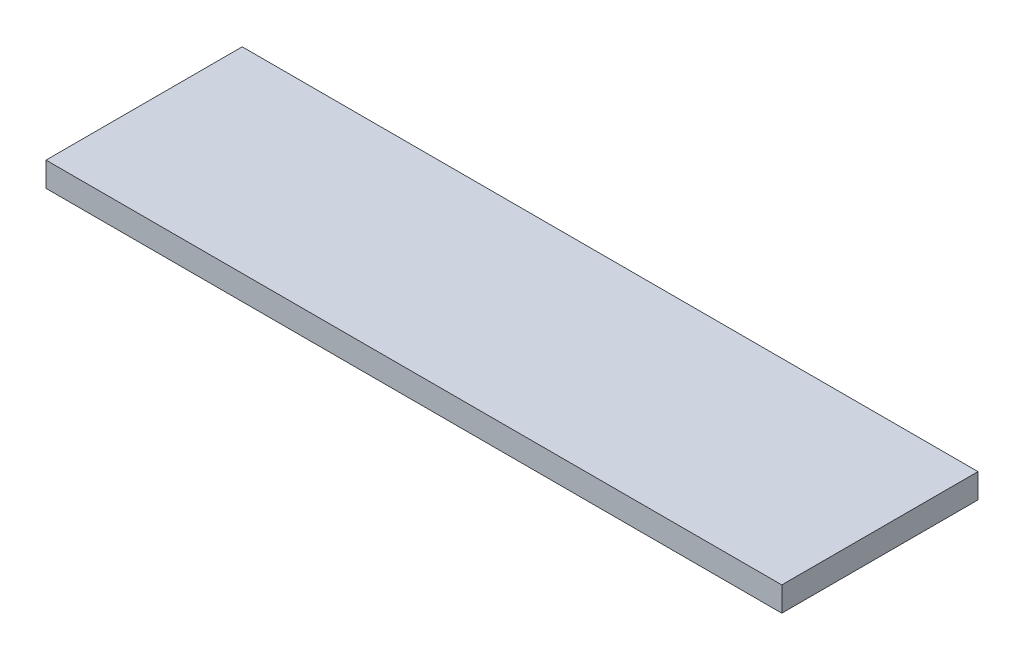
from build123d import *

# Parameters (mm, degrees)
ESBO_O7_W                = 150
ESBO_O7_H                = 5
RESSALTO_EXTRUS_O2_DEPTH = 40


with BuildPart() as part:
    # Esboço7 → Ressalto-extrusão2 (new body)
    with BuildSketch(Plane.XY):
        with Locations((8.35727616, -233.835501283)):
            Rectangle(ESBO_O7_W, ESBO_O7_H)
    extrude(amount=RESSALTO_EXTRUS_O2_DEPTH)


solid = part.part
